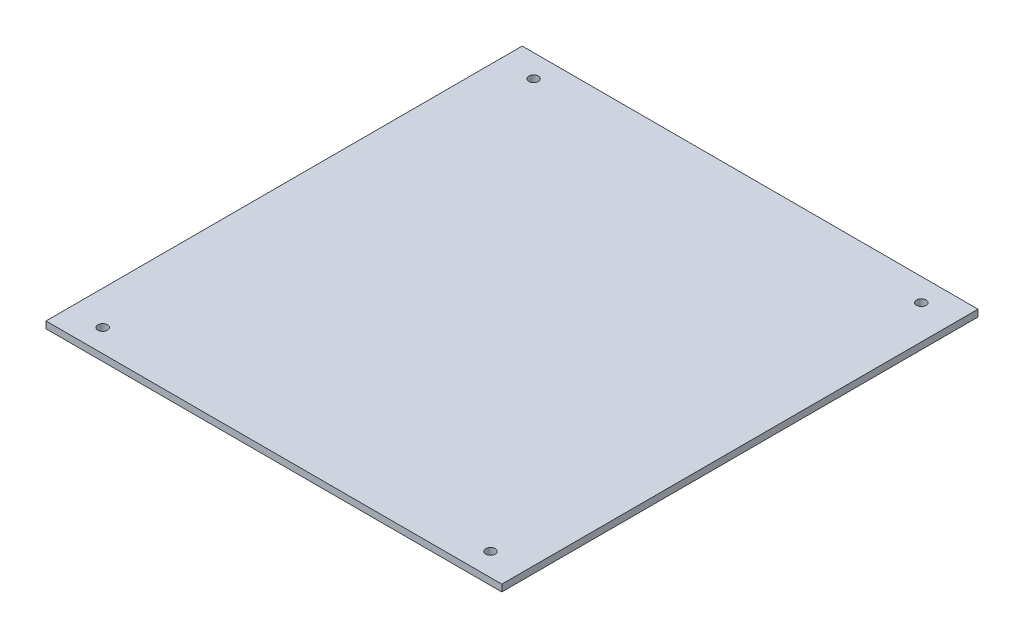
from build123d import *

# Parameters (mm, degrees)
CROQUIS1_W              = 201
CROQUIS1_H              = 210
CROQUIS1_R              = 2.1
SALIENTE_EXTRUIR1_DEPTH = 3


with BuildPart() as part:
    # Croquis1 → Saliente-Extruir1 (new body)
    with BuildSketch(Plane(origin=(0, 0, 0), x_dir=(1, 0, 0), z_dir=(0, 1, 0))):
        Rectangle(CROQUIS1_W, CROQUIS1_H)
        with Locations((-85.5, 95)):
            Circle(CROQUIS1_R, mode=Mode.SUBTRACT)
        with Locations((85.5, 95)):
            Circle(CROQUIS1_R, mode=Mode.SUBTRACT)
        with Locations((85.5, -95)):
            Circle(CROQUIS1_R, mode=Mode.SUBTRACT)
        with Locations((-85.5, -95)):
            Circle(CROQUIS1_R, mode=Mode.SUBTRACT)
    extrude(amount=SALIENTE_EXTRUIR1_DEPTH)


solid = part.part
